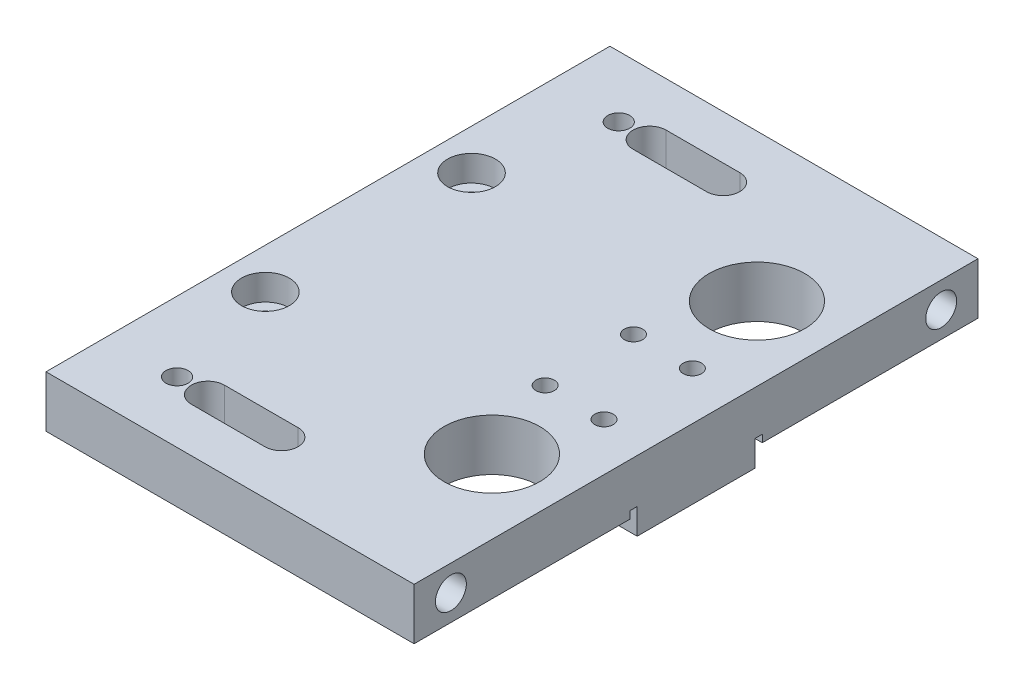
from build123d import *

# Parameters (mm, degrees)
SKETCH1_W             = 50
SKETCH1_H             = 76.6
SKETCH1_R             = 6.5
SKETCH1_R_2           = 1.75
SKETCH1_R_3           = 1.5
BOSS_EXTRUDE1_DEPTH   = 7
M5_TAPPED_HOLE1_D     = 4.2
M5_TAPPED_HOLE1_DEPTH = 10
M5_TAPPED_HOLE1_TIP   = 1.2618073
SKETCH4_R             = 3.25
CUT_EXTRUDE1_DEPTH    = 3.5
M3_TAPPED_HOLE1_D     = 2.5
M3_TAPPED_HOLE1_DEPTH = 20
M3_TAPPED_HOLE1_TIP   = 0.751075774
SKETCH10_W            = 50
SKETCH10_H            = 18
CUT_EXTRUDE3_DEPTH    = 1
SKETCH11_W            = 50
SKETCH11_H            = 16
BOSS_EXTRUDE2_DEPTH   = 3.5
M3_TAPPED_HOLE2_D     = 2.5
M3_TAPPED_HOLE2_DEPTH = 20
M3_TAPPED_HOLE2_TIP   = 0.751075774


with BuildPart() as part:
    # Sketch1 → Boss-Extrude1 (new body)
    with BuildSketch(Plane(origin=(0, 0, 0), x_dir=(1, 0, 0), z_dir=(0, 1, 0))):
        with Locations((9.743944876, -18.464670659)):
            Rectangle(SKETCH1_W, SKETCH1_H)
        with Locations((24.714004756, -0.164670659)):
            Circle(SKETCH1_R, mode=Mode.SUBTRACT)
        with Locations((24.714004756, -36.164670659)):
            Circle(SKETCH1_R, mode=Mode.SUBTRACT)
        with Locations((-9.756055124, -4.464670659)):
            Circle(SKETCH1_R_2, mode=Mode.SUBTRACT)
        with Locations((-9.756055124, -32.464670659)):
            Circle(SKETCH1_R_2, mode=Mode.SUBTRACT)
        with Locations((-5.756055124, -48.464670659)):
            Circle(SKETCH1_R_3, mode=Mode.SUBTRACT)
        with Locations((-5.756055124, 11.535329341)):
            Circle(SKETCH1_R_3, mode=Mode.SUBTRACT)
        with BuildLine():
            Line((-1.568862275, 13.785329341), (8.431137725, 13.785329341))
            ThreePointArc((8.431137725, 13.785329341), (10.681137725, 11.535329341), (8.431137725, 9.285329341))
            Line((8.431137725, 9.285329341), (-1.568862275, 9.285329341))
            ThreePointArc((-1.568862275, 9.285329341), (-3.818862275, 11.535329341), (-1.568862275, 13.785329341))
        make_face(mode=Mode.SUBTRACT)
        with BuildLine():
            Line((-1.568862275, -46.214670659), (8.431137725, -46.214670659))
            ThreePointArc((8.431137725, -46.214670659), (10.681137725, -48.464670659), (8.431137725, -50.714670659))
            Line((8.431137725, -50.714670659), (-1.568862275, -50.714670659))
            ThreePointArc((-1.568862275, -50.714670659), (-3.818862275, -48.464670659), (-1.568862275, -46.214670659))
        make_face(mode=Mode.SUBTRACT)
    extrude(amount=BOSS_EXTRUDE1_DEPTH)

    # M5 Tapped Hole1
    with Locations(Plane(origin=(34.743944876, 0, 0), x_dir=(0, 0, -1), z_dir=(1, 0, 0))):
        with Locations((14.835829661, 3.5), (-51.764670659, 3.5)):
            Hole(M5_TAPPED_HOLE1_D / 2, depth=M5_TAPPED_HOLE1_DEPTH)
            with Locations((0, 0, -(M5_TAPPED_HOLE1_DEPTH + M5_TAPPED_HOLE1_TIP / 2))):  # 118° drill point
                Cone(0, M5_TAPPED_HOLE1_D / 2, M5_TAPPED_HOLE1_TIP, mode=Mode.SUBTRACT)

    # Sketch4 → Cut-Extrude1 (cut)
    with BuildSketch(Plane(origin=(0, 7, 0), x_dir=(1, 0, 0), z_dir=(0, 1, 0))):
        with Locations((-9.756055124, -4.464670659)):
            Circle(SKETCH4_R)
        with Locations((-9.756055124, -32.464670659)):
            Circle(SKETCH4_R)
    extrude(amount=-CUT_EXTRUDE1_DEPTH, mode=Mode.SUBTRACT)

    # M3 Tapped Hole1
    with Locations(Plane(origin=(0, 7, 0), x_dir=(1, 0, 0), z_dir=(0, 1, 0))):
        with Locations((20.243944876, -12.464670659), (28.243944876, -12.464670659), (28.243944876, -24.464670659), (20.243944876, -24.464670659)):
            Hole(M3_TAPPED_HOLE1_D / 2, depth=M3_TAPPED_HOLE1_DEPTH)
            with Locations((0, 0, -(M3_TAPPED_HOLE1_DEPTH + M3_TAPPED_HOLE1_TIP / 2))):  # 118° drill point
                Cone(0, M3_TAPPED_HOLE1_D / 2, M3_TAPPED_HOLE1_TIP, mode=Mode.SUBTRACT)

    # Sketch10 → Cut-Extrude3 (cut)
    with BuildSketch(Plane.XZ):
        with Locations((9.743944876, 18.464670659)):
            Rectangle(SKETCH10_W, SKETCH10_H)
    extrude(amount=-CUT_EXTRUDE3_DEPTH, mode=Mode.SUBTRACT)

    # Sketch11 → Boss-Extrude2 (add)
    with BuildSketch(Plane.XZ.offset(-1)):
        with Locations((9.743944876, 18.464670659)):
            Rectangle(SKETCH11_W, SKETCH11_H)
    extrude(amount=BOSS_EXTRUDE2_DEPTH)

    # M3 Tapped Hole2
    with Locations(Plane(origin=(0, -2.5, 0), x_dir=(-1, 0, 0), z_dir=(0, -1, 0))):
        with Locations((-20.243944876, -12.464670659), (-28.243944876, -12.464670659), (-20.243944876, -24.464670659), (-28.243944876, -24.464670659), (-47.068271945, 0)):
            Hole(M3_TAPPED_HOLE2_D / 2, depth=M3_TAPPED_HOLE2_DEPTH)
            with Locations((0, 0, -(M3_TAPPED_HOLE2_DEPTH + M3_TAPPED_HOLE2_TIP / 2))):  # 118° drill point
                Cone(0, M3_TAPPED_HOLE2_D / 2, M3_TAPPED_HOLE2_TIP, mode=Mode.SUBTRACT)


solid = part.part
